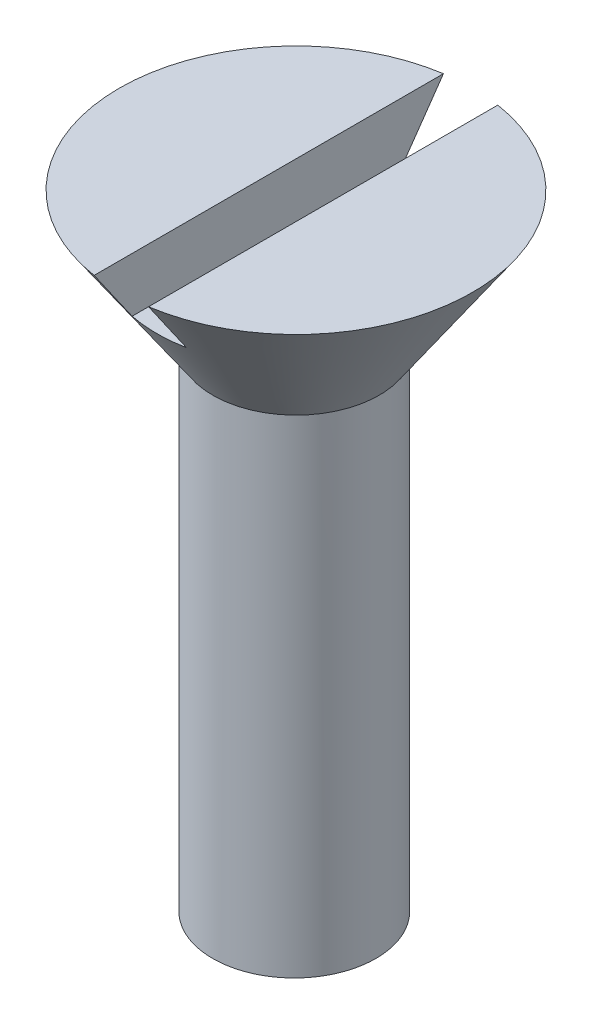
from build123d import *

# Parameters (mm, degrees)
SKETCH1_W               = 3
SKETCH1_H               = 18
CUT_EXTRUDE1_DEPTH      = 7.5
CUT_EXTRUDE1_DEPTH_BACK = 7.5


with BuildPart() as part:
    # Sketch1 → Revolve2 (revolve)
    with BuildSketch(Plane.XY):
        with Locations((-1.562240664, 0)):
            Rectangle(SKETCH1_W, SKETCH1_H)
    revolve(axis=Axis((-0.062240664, 9, 0), (0, -1, 0)))

    # Sketch3 → Revolve3 (revolve)
    with BuildSketch(Plane.XY):
        Polygon((3.062240664, 9), (0, 9), (0, 14), (6.5, 14), align=None)
    revolve(axis=Axis((0, 14, 0), (0, -1, 0)))

    # Sketch4 → Cut-Extrude1 (cut, two sides)
    with BuildSketch(Plane.XY) as cut_extrude1_sk:
        Polygon((1, 72.383881614), (1, 14), (1, 12), (-1, 12), (-1, 14), (-1, 72.383881614), (-1, 189.151644841), (1, 189.151644841), align=None)
    extrude(amount=CUT_EXTRUDE1_DEPTH, mode=Mode.SUBTRACT)
    extrude(cut_extrude1_sk.sketch, amount=-CUT_EXTRUDE1_DEPTH_BACK, mode=Mode.SUBTRACT)

    # Sketch5 → Revolve4 (revolve)
    with BuildSketch(Plane.XY):
        Polygon((2.937759336, -9), (0, -10.696116144), (0, -9), align=None)
    revolve(axis=Axis((0, -10.696116144, 0), (0, 1, 0)))


solid = part.part
